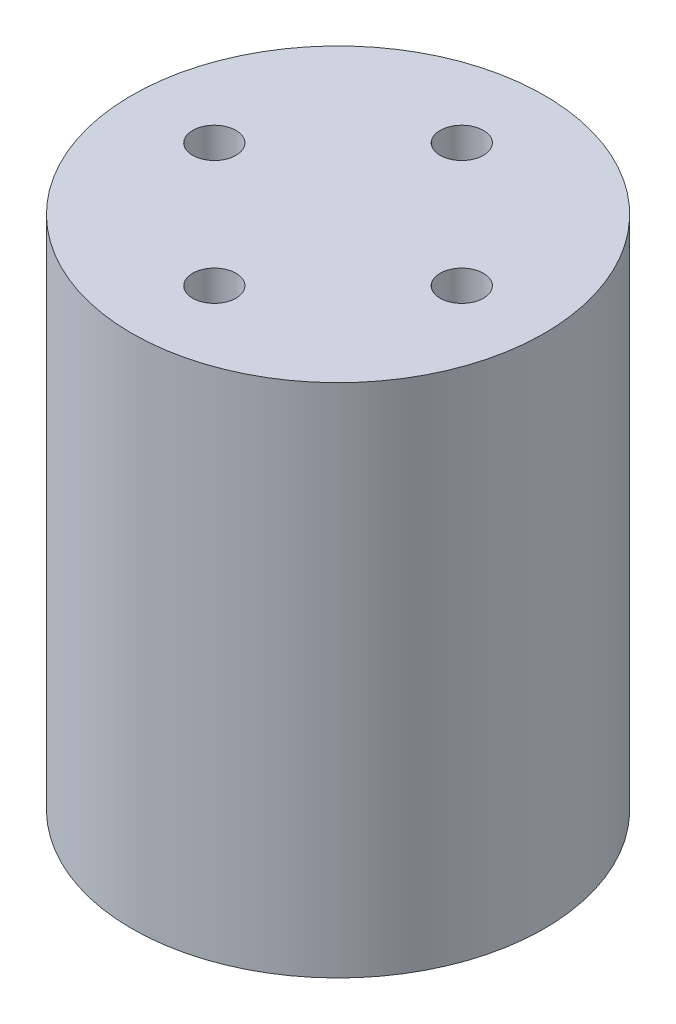
from build123d import *

# Parameters (mm, degrees)
SKETCH1_R                 = 20
BOSS_EXTRUDE1_DEPTH       = 25
M5X0_8_TAPPED_HOLE1_D     = 4.2
M5X0_8_TAPPED_HOLE1_DEPTH = 18.7381927
M5X0_8_TAPPED_HOLE1_TIP   = 1.2618073


with BuildPart() as part:
    # Sketch1 → Boss-Extrude1 (new body, symmetric)
    with BuildSketch(Plane(origin=(0, 0, 0), x_dir=(1, 0, 0), z_dir=(0, 1, 0))):
        Circle(SKETCH1_R)
    extrude(amount=BOSS_EXTRUDE1_DEPTH, both=True)

    # M5x0.8 Tapped Hole1
    with Locations(Plane(origin=(0, 25, -12), x_dir=(0, 0, 1), z_dir=(0, 1, 0))):
        with Locations((0, 0), (12, 12), (24, 0), (12, -12)):
            Hole(M5X0_8_TAPPED_HOLE1_D / 2, depth=M5X0_8_TAPPED_HOLE1_DEPTH)
            with Locations((0, 0, -(M5X0_8_TAPPED_HOLE1_DEPTH + M5X0_8_TAPPED_HOLE1_TIP / 2))):  # 118° drill point
                Cone(0, M5X0_8_TAPPED_HOLE1_D / 2, M5X0_8_TAPPED_HOLE1_TIP, mode=Mode.SUBTRACT)


solid = part.part
